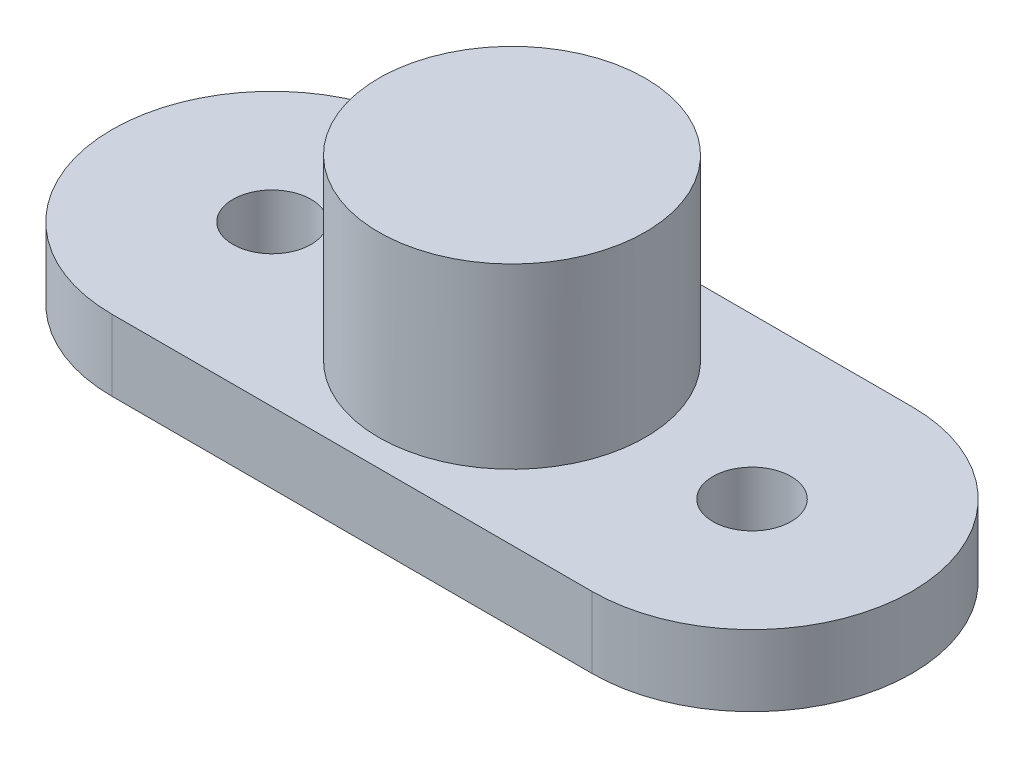
from build123d import *

# Parameters (mm, degrees)
SKETCH1_R           = 1.1
SKETCH1_R_2         = 3.75
BOSS_EXTRUDE3_DEPTH = 2
SKETCH3_R           = 3.75
BOSS_EXTRUDE4_DEPTH = 7


with BuildPart() as part:
    # Sketch1 → Boss-Extrude3 (new body)
    with BuildSketch(Plane(origin=(0, 0, 0), x_dir=(1, 0, 0), z_dir=(0, 1, 0))):
        with BuildLine():
            Line((-6.75, 4.499502967), (6.75, 4.499502967))
            ThreePointArc((6.75, 4.499502967), (11.249502967, 0), (6.75, -4.499502967))
            Line((6.75, -4.499502967), (-6.75, -4.499502967))
            ThreePointArc((-6.75, -4.499502967), (-11.249502967, 0), (-6.75, 4.499502967))
        make_face()
        with Locations((-6.75, 0)):
            Circle(SKETCH1_R, mode=Mode.SUBTRACT)
        with Locations((6.75, 0)):
            Circle(SKETCH1_R, mode=Mode.SUBTRACT)
        Circle(SKETCH1_R_2, mode=Mode.SUBTRACT)
    extrude(amount=BOSS_EXTRUDE3_DEPTH)

    # Sketch3 → Boss-Extrude4 (add)
    with BuildSketch(Plane.XZ):
        Circle(SKETCH3_R)
    extrude(amount=-BOSS_EXTRUDE4_DEPTH)


solid = part.part
